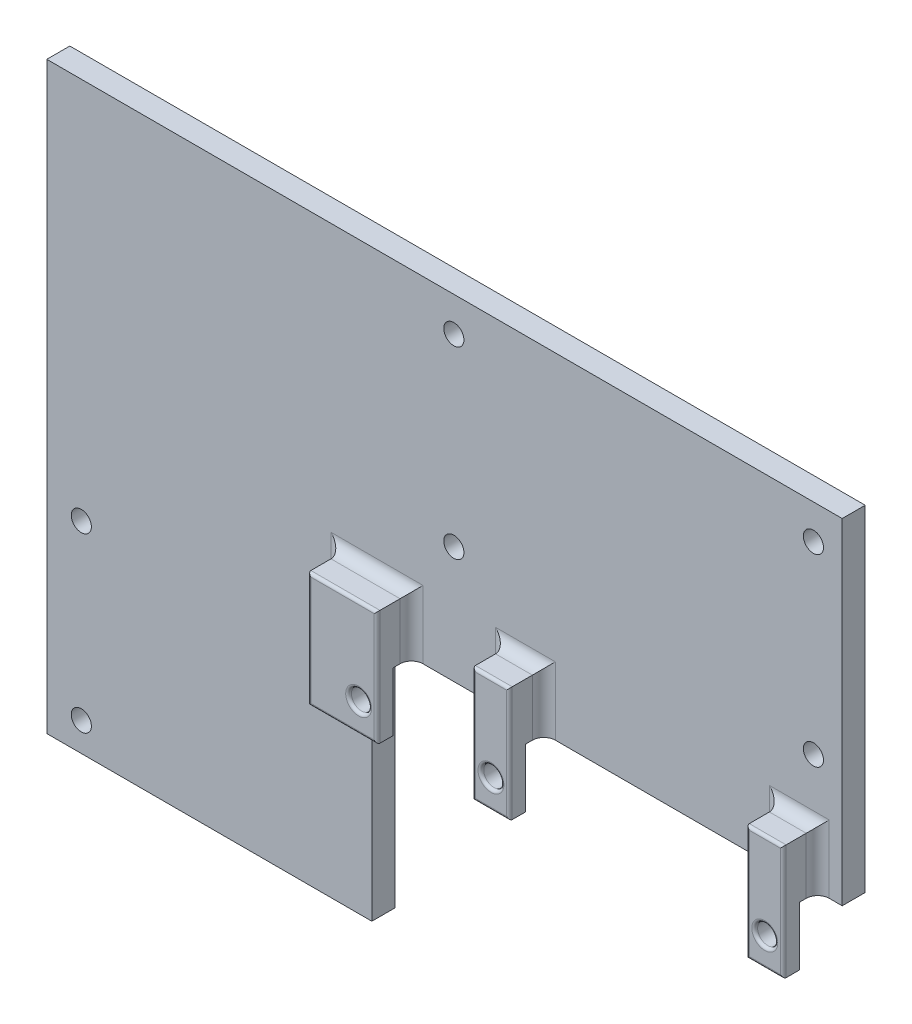
from build123d import *

# Parameters (mm, degrees)
SKETCH_1_W          = 138.25
SKETCH_1_H          = 101.5
EXTRUDE_1_DEPTH     = 4
SKETCH_2_W          = 81.75
SKETCH_2_H          = 43.2
CUT_EXTRUDE_1_DEPTH = 5
SKETCH_3_R          = 1.75
CUT_EXTRUDE_2_DEPTH = 5
SKETCH_4_W          = 6.4
SKETCH_4_H          = 20
SKETCH_4_R          = 1.75
SKETCH_4_W_2        = 12
EXTRUDE_6_DEPTH     = 6
FILLET_3_R          = 2
SKETCH_5_W          = 3.2
SKETCH_5_H          = 10.2
CUT_EXTRUDE_3_DEPTH = 81.75
FILLET_4_R          = 0.5


with BuildPart() as part:
    # ｽｹｯﾁ1 → ﾎﾞｽ - 押し出し1 (new body)
    with BuildSketch(Plane.XY):
        Rectangle(SKETCH_1_W, SKETCH_1_H)
    extrude(amount=EXTRUDE_1_DEPTH)

    # ｽｹｯﾁ2 → ｶｯﾄ - 押し出し1 (cut, through all)
    with BuildSketch(Plane.XY.offset(4)):
        with Locations((28.25, -29.15)):
            Rectangle(SKETCH_2_W, SKETCH_2_H)
    extrude(amount=-CUT_EXTRUDE_1_DEPTH, mode=Mode.SUBTRACT)

    # ｽｹｯﾁ3 → ｶｯﾄ - 押し出し2 (cut, through all)
    with BuildSketch(Plane.XY.offset(4)):
        with Locations((-63.125, -45.75)):
            Circle(SKETCH_3_R)
        with Locations((-63.125, -15.75)):
            Circle(SKETCH_3_R)
        with Locations((64.125, 44.75)):
            Circle(SKETCH_3_R)
        with Locations((64.125, 12.75)):
            Circle(SKETCH_3_R)
        with Locations((1.625, 44.75)):
            Circle(SKETCH_3_R)
        with Locations((1.625, 12.75)):
            Circle(SKETCH_3_R)
    extrude(amount=-CUT_EXTRUDE_2_DEPTH, mode=Mode.SUBTRACT)

    # ｽｹｯﾁ4 → ﾎﾞｽ - 押し出し6 (add)
    with BuildSketch(Plane.XY.offset(4)):
        with Locations((61.675, -7.75)):
            Rectangle(SKETCH_4_W, SKETCH_4_H)
        with Locations((61.675, -12.75)):
            Circle(SKETCH_4_R, mode=Mode.SUBTRACT)
        with Locations((14.075, -7.75)):
            Rectangle(SKETCH_4_W, SKETCH_4_H)
        with Locations((14.075, -12.75)):
            Circle(SKETCH_4_R, mode=Mode.SUBTRACT)
        with Locations((-11.725, -7.75)):
            Rectangle(SKETCH_4_W_2, SKETCH_4_H)
        with Locations((-8.925, -12.75)):
            Circle(SKETCH_4_R, mode=Mode.SUBTRACT)
    extrude(amount=EXTRUDE_6_DEPTH)

    # ﾌｨﾚｯﾄ3
    fillet_3_edges = [part.edges().sort_by_distance(p)[0] for p in [
        (64.875, -2.65, 4),
        (61.675, 2.25, 4),
        (58.475, -2.65, 4),
        (17.275, -2.65, 4),
        (14.075, 2.25, 4),
        (10.875, -2.65, 4),
        (-5.725, -2.65, 4),
        (-11.725, 2.25, 4),
        (-17.725, -7.75, 4),
    ]]
    fillet(fillet_3_edges, radius=FILLET_3_R)

    # ｽｹｯﾁ5 → ｶｯﾄ - 押し出し3 (cut)
    with BuildSketch(Plane(origin=(69.125, 0, 0), x_dir=(0, 0, -1), z_dir=(1, 0, 0))):
        with Locations((-5.6, -12.65)):
            Rectangle(SKETCH_5_W, SKETCH_5_H)
    extrude(amount=-CUT_EXTRUDE_3_DEPTH, mode=Mode.SUBTRACT)

    # ﾌｨﾚｯﾄ4
    fillet_4_edges = [part.edges().sort_by_distance(p)[0] for p in [
        (64.875, -7.75, 10),
        (61.675, 2.25, 10),
        (58.475, -7.75, 10),
        (61.675, -17.75, 10),
        (59.925, -12.75, 10),
        (17.275, -7.75, 10),
        (14.075, 2.25, 10),
        (10.875, -7.75, 10),
        (14.075, -17.75, 10),
        (12.325, -12.75, 10),
        (-5.725, -7.75, 10),
        (-11.725, 2.25, 10),
        (-17.725, -7.75, 10),
        (-11.725, -17.75, 10),
        (-10.675, -12.75, 10),
    ]]
    fillet(fillet_4_edges, radius=FILLET_4_R)


solid = part.part
